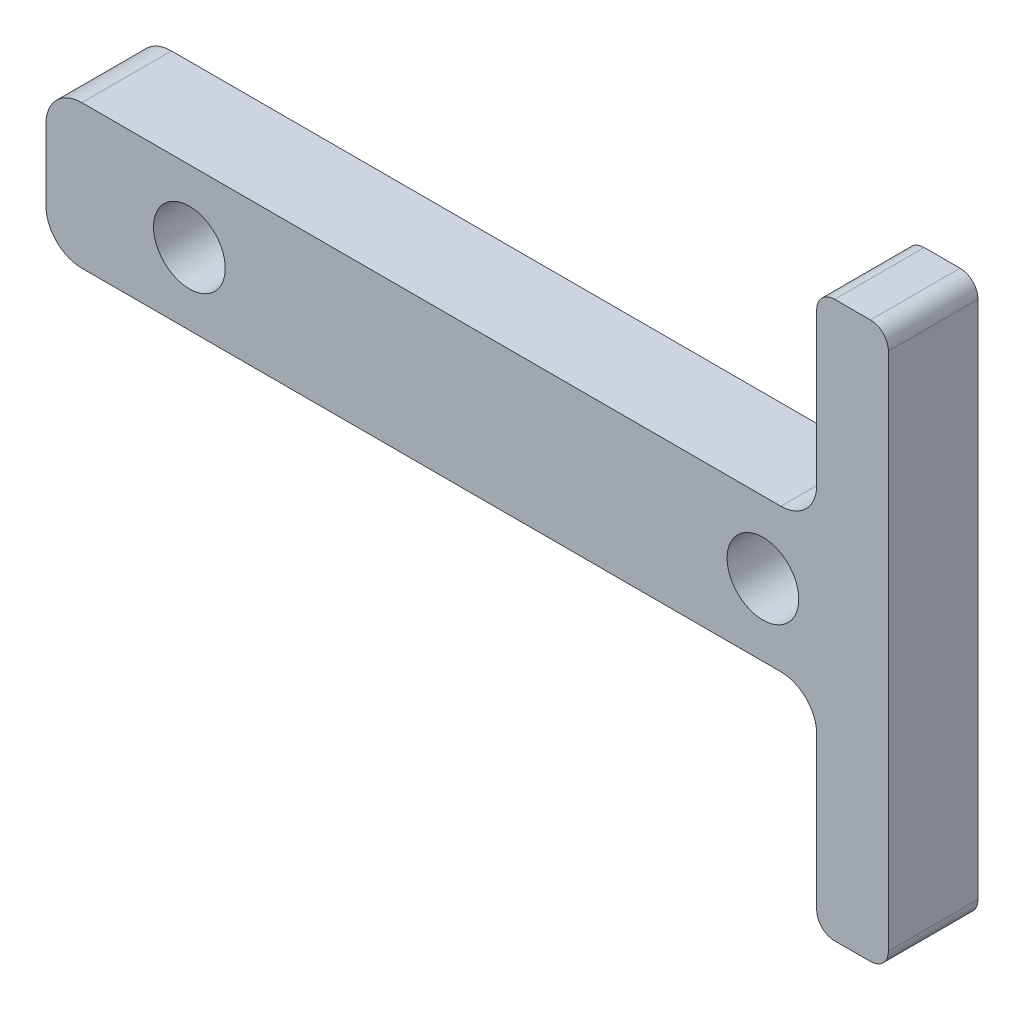
from build123d import *

# Parameters (mm, degrees)
BOSS_EXTRUDE1_DEPTH = 5
SKETCH2_R           = 2
CUT_EXTRUDE1_DEPTH  = 6


with BuildPart() as part:
    # Sketch1 → Boss-Extrude1 (new body)
    with BuildSketch(Plane.XY):
        with BuildLine():
            Line((-19.5, 0), (19.5, 0))
            ThreePointArc((19.5, 0), (20.914213562, 0.585786438), (21.5, 2))
            Line((21.5, 2), (21.5, 10.5))
            ThreePointArc((21.5, 10.5), (21.792893219, 11.207106781), (22.5, 11.5))
            Line((22.5, 11.5), (24.5, 11.5))
            ThreePointArc((24.5, 11.5), (25.207106781, 11.207106781), (25.5, 10.5))
            Line((25.5, 10.5), (25.5, -18.5))
            ThreePointArc((25.5, -18.5), (25.207106781, -19.207106781), (24.5, -19.5))
            Line((24.5, -19.5), (22.5, -19.5))
            ThreePointArc((22.5, -19.5), (21.792893219, -19.207106781), (21.5, -18.5))
            Line((21.5, -18.5), (21.5, -10))
            ThreePointArc((21.5, -10), (20.914213562, -8.585786438), (19.5, -8))
            Line((19.5, -8), (-19.5, -8))
            ThreePointArc((-19.5, -8), (-20.914213562, -7.414213562), (-21.5, -6))
            Line((-21.5, -6), (-21.5, -2))
            ThreePointArc((-21.5, -2), (-20.914213562, -0.585786438), (-19.5, 0))
        make_face()
    extrude(amount=BOSS_EXTRUDE1_DEPTH)

    # Sketch2 → Cut-Extrude1 (cut, through all)
    with BuildSketch(Plane.XY.offset(5)):
        with Locations((-13.5, -4)):
            Circle(SKETCH2_R)
        with Locations((18.5, -4)):
            Circle(SKETCH2_R)
    extrude(amount=-CUT_EXTRUDE1_DEPTH, mode=Mode.SUBTRACT)


solid = part.part
